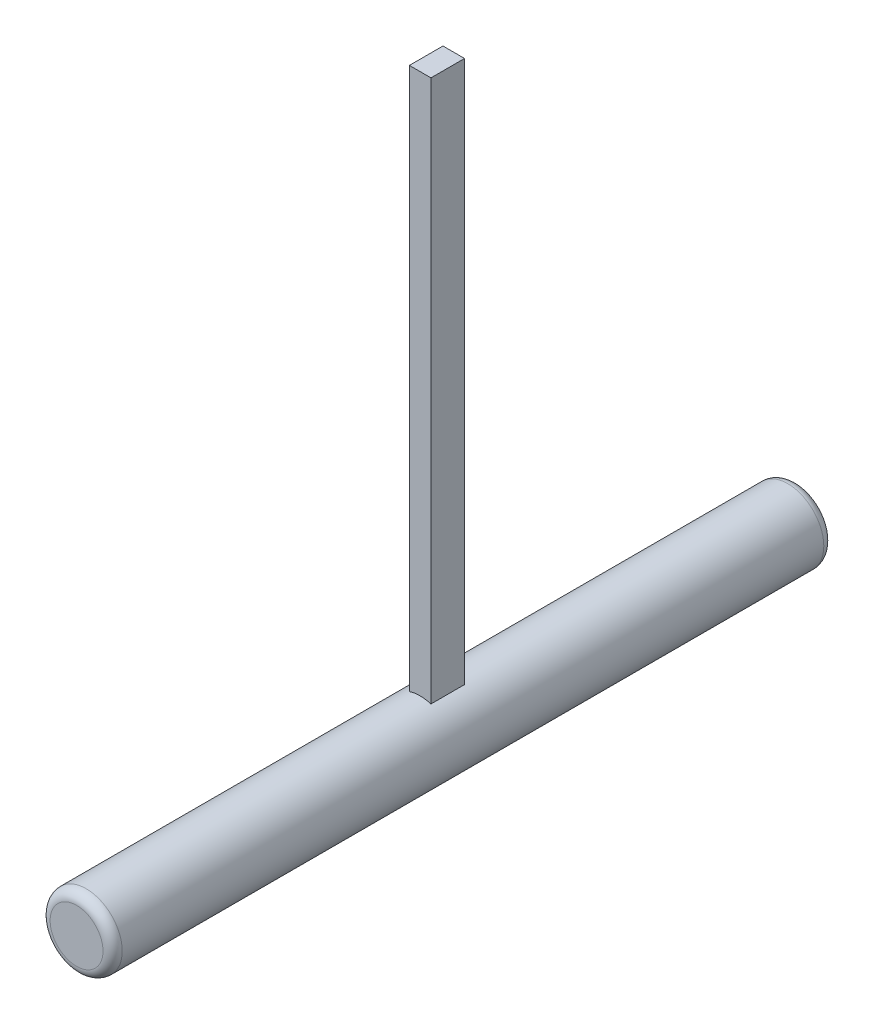
from build123d import *

# Parameters (mm, degrees)
SKETCH1_R           = 7.5
BOSS_EXTRUDE1_DEPTH = 150
FILLET1_R           = 2
BOSS_EXTRUDE2_REACH = 129.5
SKETCH3_W           = 4.49
SKETCH3_H           = 6.99


with BuildPart() as part:
    # Sketch1 → Boss-Extrude1 (new body)
    with BuildSketch(Plane.XY):
        Circle(SKETCH1_R)
    extrude(amount=BOSS_EXTRUDE1_DEPTH)

    # Fillet1
    fillet1_edges = [part.edges().sort_by_distance(p)[0] for p in [
        (-7.5, 0, 0),
        (-7.5, 0, 150),
    ]]
    fillet(fillet1_edges, radius=FILLET1_R)

    # Sketch3 → Boss-Extrude2 (add, up to next)
    with BuildSketch(Plane(origin=(0, 120, 0), x_dir=(1, 0, 0), z_dir=(0, 1, 0)), mode=Mode.PRIVATE) as boss_extrude2_sk1:
        with Locations((0, -75)):
            Rectangle(SKETCH3_W, SKETCH3_H)
    boss_extrude2_tool1 = extrude(boss_extrude2_sk1.sketch, amount=-BOSS_EXTRUDE2_REACH, mode=Mode.PRIVATE) - part.part
    add(boss_extrude2_tool1.solids().sort_by_distance((0, 120, 75))[0])


solid = part.part
